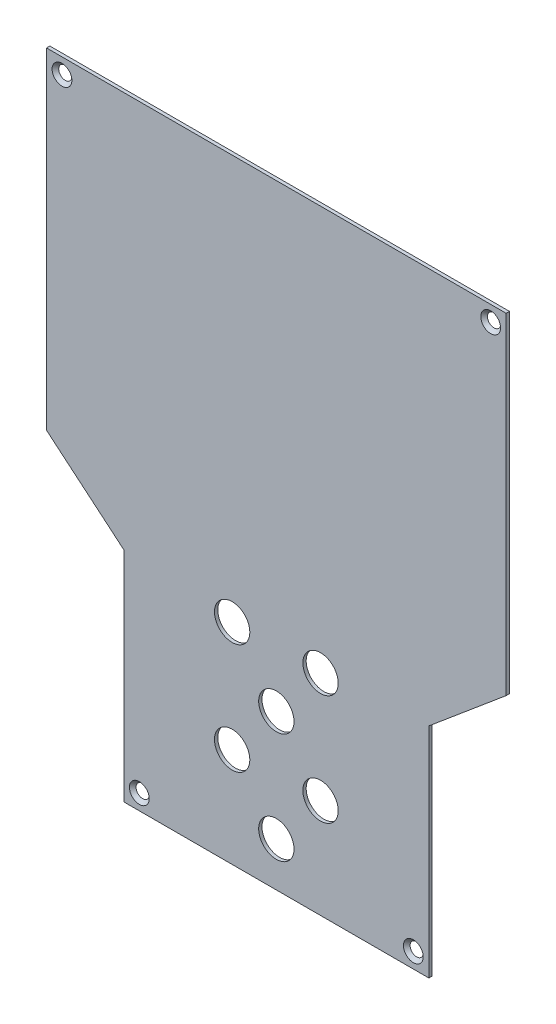
from build123d import *

# Parameters (mm, degrees)
RESSALTO_EXTRUS_O1_DEPTH                     = 1.5
ESBO_O2_R                                    = 8
CORTE_EXTRUS_O1_DEPTH                        = 2.5
ESCAREADO_PARA_PARAFUSO_ALLEN_SEXTAV_2_COUNT = 2
ESCAREADO_PARA_PARAFUSO_ALLEN_SEXTAV_2_PITCH = 194
ESCAREADO_PARA_PARAFUSO_ALLEN_SEXTAV_3_COUNT = 2
ESCAREADO_PARA_PARAFUSO_ALLEN_SEXTAV_3_PITCH = 308.183386963
ESCAREADO_PARA_PARAFUSO_ALLEN_SEXTAV_4_COUNT = 2
ESCAREADO_PARA_PARAFUSO_ALLEN_SEXTAV_4_PITCH = 266.309969772


with BuildPart() as part:
    # Esboço1 → Ressalto-extrusão1 (new body)
    with BuildSketch(Plane.XY):
        Polygon((100.860947645, 140.996609125), (-107.139052355, 140.996609125), (-107.139052355, -8.842442963), (-72.139052355, -38.210930054), (-72.139052355, -137.003390875), (65.860947645, -137.003390875), (65.860947645, -38.210930054), (100.860947645, -8.842442963), align=None)
    extrude(amount=RESSALTO_EXTRUS_O1_DEPTH)

    # Esboço2 → Corte-extrusão1 (cut, through all)
    with BuildSketch(Plane.XY.offset(1.5)):
        with Locations((-3.139052355, -117.003390875)):
            Circle(ESBO_O2_R)
        with Locations((16.860947645, -42.003390875)):
            Circle(ESBO_O2_R)
        with Locations((-23.139052355, -92.003390875)):
            Circle(ESBO_O2_R)
        with Locations((-3.139052355, -67.003390875)):
            Circle(ESBO_O2_R)
        with Locations((16.860947645, -92.003390875)):
            Circle(ESBO_O2_R)
        with Locations((-23.139052355, -42.003390875)):
            Circle(ESBO_O2_R)
    extrude(amount=-CORTE_EXTRUS_O1_DEPTH, mode=Mode.SUBTRACT)

    # Esboço4 → Escareado para parafuso Allen sextavado escareado de M41 (revolve, cut)
    with BuildSketch(Plane(origin=(-100.139052355, 133.996609125, 1.5), x_dir=(0, -1, 0), z_dir=(1, 0, 0))):
        Polygon((0, 0), (0, 1.5), (2.25, 1.5), (2.25, 2.23), (4.48, 0), align=None)
    escareado_para_parafuso_allen_sextavado = revolve(axis=Axis((-100.139052355, 133.996609125, 7.85), (0, 0, -1)), mode=Mode.SUBTRACT)

    # Escareado para parafuso Allen sextav 2: Escareado para parafuso Allen sextavado escareado de M41 ×2
    with Locations(*[(i * ESCAREADO_PARA_PARAFUSO_ALLEN_SEXTAV_2_PITCH, 0, 0) for i in range(1, ESCAREADO_PARA_PARAFUSO_ALLEN_SEXTAV_2_COUNT)]):
        add(escareado_para_parafuso_allen_sextavado, mode=Mode.SUBTRACT)

    # Escareado para parafuso Allen sextav 3: Escareado para parafuso Allen sextavado escareado de M41 ×2
    with Locations(*[Vector(0.515926577, -0.856632808, 0) * (i * ESCAREADO_PARA_PARAFUSO_ALLEN_SEXTAV_3_PITCH) for i in range(1, ESCAREADO_PARA_PARAFUSO_ALLEN_SEXTAV_3_COUNT)]):
        add(escareado_para_parafuso_allen_sextavado, mode=Mode.SUBTRACT)

    # Escareado para parafuso Allen sextav 4: Escareado para parafuso Allen sextavado escareado de M41 ×2
    with Locations(*[Vector(0.131425797, -0.991326011, 0) * (i * ESCAREADO_PARA_PARAFUSO_ALLEN_SEXTAV_4_PITCH) for i in range(1, ESCAREADO_PARA_PARAFUSO_ALLEN_SEXTAV_4_COUNT)]):
        add(escareado_para_parafuso_allen_sextavado, mode=Mode.SUBTRACT)


solid = part.part
